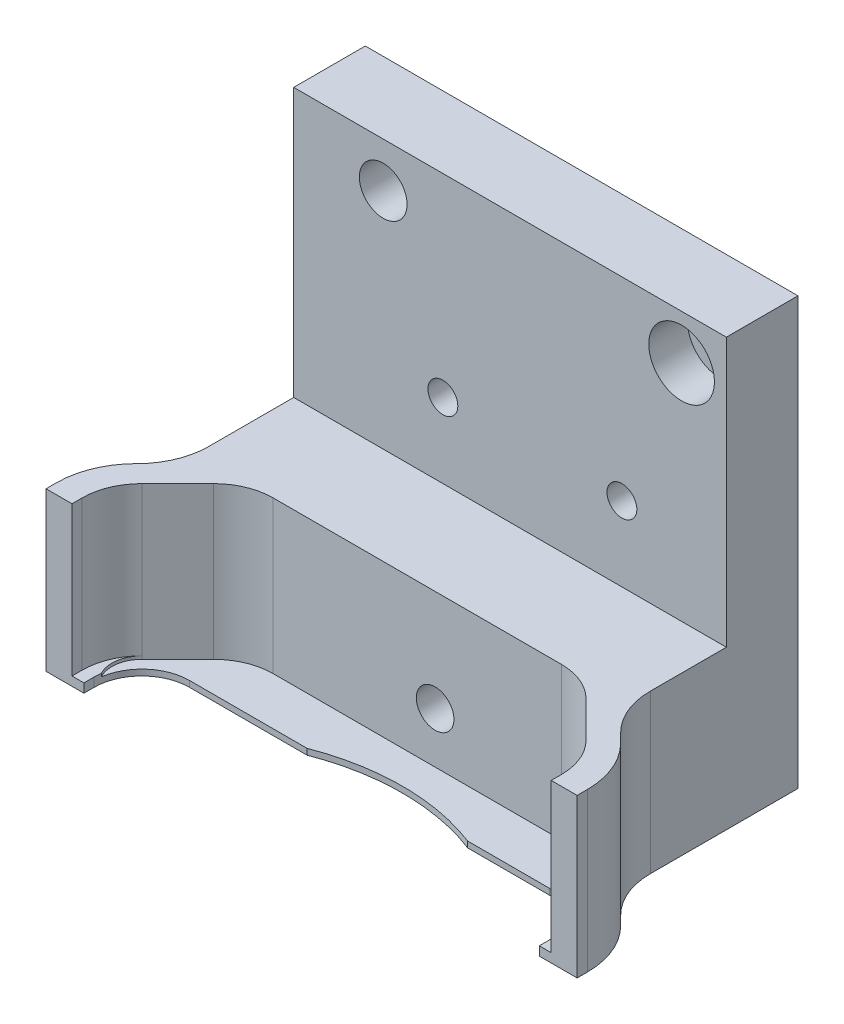
from build123d import *

# Parameters (mm, degrees)
SKIZZE1_W                       = 89
SKIZZE1_H                       = 71.5
LINEAR_AUSTRAGEN1_DEPTH         = 46
SKIZZE12_W                      = 89
SKIZZE12_H                      = 40.19389994
LINEAR_AUSTRAGEN2_DEPTH         = 45
LINEAR_AUSTRAGEN3_DEPTH         = 25
LINEAR_AUSTRAGEN9_DEPTH         = 1.5
SCHNITT_LINEAR_AUSTRAGEN1_DEPTH = 0.5
SKIZZE3_R                       = 1.5
SKIZZE3_R_2                     = 2.15
SKIZZE3_R_3                     = 3.2
LINEAR_AUSTRAGEN4_DEPTH         = 47
SKIZZE4_R                       = 4
SKIZZE4_R_2                     = 5.5
LINEAR_AUSTRAGEN5_DEPTH         = 6.5
SKIZZE13_R                      = 2.5
LINEAR_AUSTRAGEN8_DEPTH         = 8
SKIZZE10_R                      = 3.15
LINEAR_AUSTRAGEN6_DEPTH         = 28.3
SKIZZE11_R                      = 5.5
LINEAR_AUSTRAGEN7_DEPTH         = 23.3
LINEAR_AUSTRAGEN10_DEPTH        = 71.5


with BuildPart() as part:
    # Skizze1 → Linear austragen1 (new body)
    with BuildSketch(Plane.XY):
        with Locations((-3, 35.75)):
            Rectangle(SKIZZE1_W, SKIZZE1_H)
    extrude(amount=LINEAR_AUSTRAGEN1_DEPTH)

    # Skizze12 → Linear austragen2 (cut)
    with BuildSketch(Plane(origin=(0, 71.5, 0), x_dir=(1, 0, 0), z_dir=(0, 1, 0))):
        with Locations((-3, -32.09694997)):
            Rectangle(SKIZZE12_W, SKIZZE12_H)
    extrude(amount=-LINEAR_AUSTRAGEN2_DEPTH, mode=Mode.SUBTRACT)

    # Skizze2 → Linear austragen3 (cut)
    with BuildSketch(Plane.XZ.offset(-26.5)):
        with BuildLine():
            Line((-43.15, 46), (37.15, 46))
            Line((37.15, 46), (37.15, 44.3))
            ThreePointArc((37.15, 44.3), (36.388795325, 40.473165676), (34.221067812, 37.228932188))
            Line((34.221067812, 37.228932188), (28.221067812, 31.228932188))
            ThreePointArc((28.221067812, 31.228932188), (24.976834324, 29.061204675), (21.15, 28.3))
            Line((21.15, 28.3), (-27.15, 28.3))
            ThreePointArc((-27.15, 28.3), (-30.976834324, 29.061204675), (-34.221067812, 31.228932188))
            Line((-34.221067812, 31.228932188), (-40.221067812, 37.228932188))
            ThreePointArc((-40.221067812, 37.228932188), (-42.388795325, 40.473165676), (-43.15, 44.3))
            Line((-43.15, 44.3), (-43.15, 46))
        make_face()
    extrude(amount=LINEAR_AUSTRAGEN3_DEPTH, mode=Mode.SUBTRACT)

    # Skizze14 → Linear austragen9 (cut)
    with BuildSketch(Plane(origin=(0, 1.5, 0), x_dir=(-1, 0, 0), z_dir=(0, 1, 0))):
        with BuildLine():
            Line((13.462912018, 36.3), (33.15, 36.3))
            ThreePointArc((33.15, 36.3), (38.806854249, 38.643145751), (41.15, 44.3))
            Line((41.15, 44.3), (41.15, 46))
            Line((41.15, 46), (-35.15, 46))
            Line((-35.15, 46), (-35.15, 44.3))
            ThreePointArc((-35.15, 44.3), (-32.806854249, 38.643145751), (-27.15, 36.3))
            Line((-27.15, 36.3), (-13.462912018, 36.3))
            ThreePointArc((-13.462912018, 36.3), (0, 33.8), (13.462912018, 36.3))
        make_face()
    extrude(amount=-LINEAR_AUSTRAGEN9_DEPTH, mode=Mode.SUBTRACT)

    # Skizze16 → Schnitt-Linear austragen1 (cut)
    with BuildSketch(Plane(origin=(0, 1.5, 0), x_dir=(1, 0, 0), z_dir=(0, 1, 0))):
        with BuildLine():
            Line((21.15, -28.3), (-27.15, -28.3))
            ThreePointArc((-27.15, -28.3), (-30.976834324, -29.061204675), (-34.221067812, -31.228932188))
            Line((-34.221067812, -31.228932188), (-40.221067812, -37.228932188))
            ThreePointArc((-40.221067812, -37.228932188), (-41.635281374, -40.057359313), (-41.069595949, -43.16862915))
            ThreePointArc((-41.069595949, -43.16862915), (-38.391613931, -38.25636836), (-33.15, -36.3))
            Line((-33.15, -36.3), (-13.462912018, -36.3))
            ThreePointArc((-13.462912018, -36.3), (0, -33.8), (13.462912018, -36.3))
            Line((13.462912018, -36.3), (27.15, -36.3))
            ThreePointArc((27.15, -36.3), (32.391613931, -38.25636836), (35.069595949, -43.16862915))
            ThreePointArc((35.069595949, -43.16862915), (35.635281374, -40.057359313), (34.221067812, -37.228932188))
            Line((34.221067812, -37.228932188), (28.221067812, -31.228932188))
            ThreePointArc((28.221067812, -31.228932188), (24.976834324, -29.061204675), (21.15, -28.3))
        make_face()
    extrude(amount=-SCHNITT_LINEAR_AUSTRAGEN1_DEPTH, mode=Mode.SUBTRACT)

    # Skizze3 → Linear austragen4 (cut, through all)
    with BuildSketch(Plane(origin=(0, 0, 0), x_dir=(-1, 0, 0), z_dir=(0, 0, -1))):
        with Locations((15, 39)):
            Circle(SKIZZE3_R)
        with Locations((-15, 39)):
            Circle(SKIZZE3_R)
        with Locations((25, 64)):
            Circle(SKIZZE3_R_2)
        with Locations((-25, 64)):
            Circle(SKIZZE3_R_3)
    extrude(amount=-LINEAR_AUSTRAGEN4_DEPTH, mode=Mode.SUBTRACT)

    # Skizze4 → Linear austragen5 (cut)
    with BuildSketch(Plane(origin=(0, 0, 12), x_dir=(-1, 0, 0), z_dir=(0, 0, -1))):
        with Locations((25, 64)):
            Circle(SKIZZE4_R)
        with Locations((-25, 64)):
            Circle(SKIZZE4_R_2)
    extrude(amount=LINEAR_AUSTRAGEN5_DEPTH, mode=Mode.SUBTRACT)

    # Skizze13 → Linear austragen8 (cut)
    with BuildSketch(Plane.XY.offset(12)):
        with Locations((15, 39)):
            Circle(SKIZZE13_R)
        with Locations((-15, 39)):
            Circle(SKIZZE13_R)
    extrude(amount=-LINEAR_AUSTRAGEN8_DEPTH, mode=Mode.SUBTRACT)

    # Skizze10 → Linear austragen6 (cut)
    with BuildSketch(Plane(origin=(0, 0, 0), x_dir=(-1, 0, 0), z_dir=(0, 0, -1))):
        with Locations((0, 9.5)):
            Circle(SKIZZE10_R)
    extrude(amount=-LINEAR_AUSTRAGEN6_DEPTH, mode=Mode.SUBTRACT)

    # Skizze11 → Linear austragen7 (cut)
    with BuildSketch(Plane(origin=(0, 0, 0), x_dir=(-1, 0, 0), z_dir=(0, 0, -1))):
        with Locations((0, 9.5)):
            Circle(SKIZZE11_R)
    extrude(amount=-LINEAR_AUSTRAGEN7_DEPTH, mode=Mode.SUBTRACT)

    # Skizze15 → Linear austragen10 (cut)
    with BuildSketch(Plane.XZ):
        with BuildLine():
            Line((41.5, 44.3), (41.5, 0))
            Line((41.5, 0), (32.5, 0))
            Line((32.5, 0), (32.5, 24.737554159))
            ThreePointArc((32.5, 24.737554159), (33.41344561, 29.329755348), (36.014718626, 33.222835534))
            Line((36.014718626, 33.222835534), (37.545941546, 34.754058454))
            ThreePointArc((37.545941546, 34.754058454), (40.472373689, 39.133773663), (41.5, 44.3))
        make_face()
        with BuildLine():
            Line((-47.5, 44.3), (-47.5, 0))
            Line((-47.5, 0), (-40, 0))
            Line((-40, 0), (-40, 26.237554159))
            ThreePointArc((-40, 26.237554159), (-40.91344561, 30.829755348), (-43.514718626, 34.722835534))
            Line((-43.514718626, 34.722835534), (-43.545941546, 34.754058454))
            ThreePointArc((-43.545941546, 34.754058454), (-46.472373689, 39.133773663), (-47.5, 44.3))
        make_face()
    extrude(amount=-LINEAR_AUSTRAGEN10_DEPTH, mode=Mode.SUBTRACT)


solid = part.part
